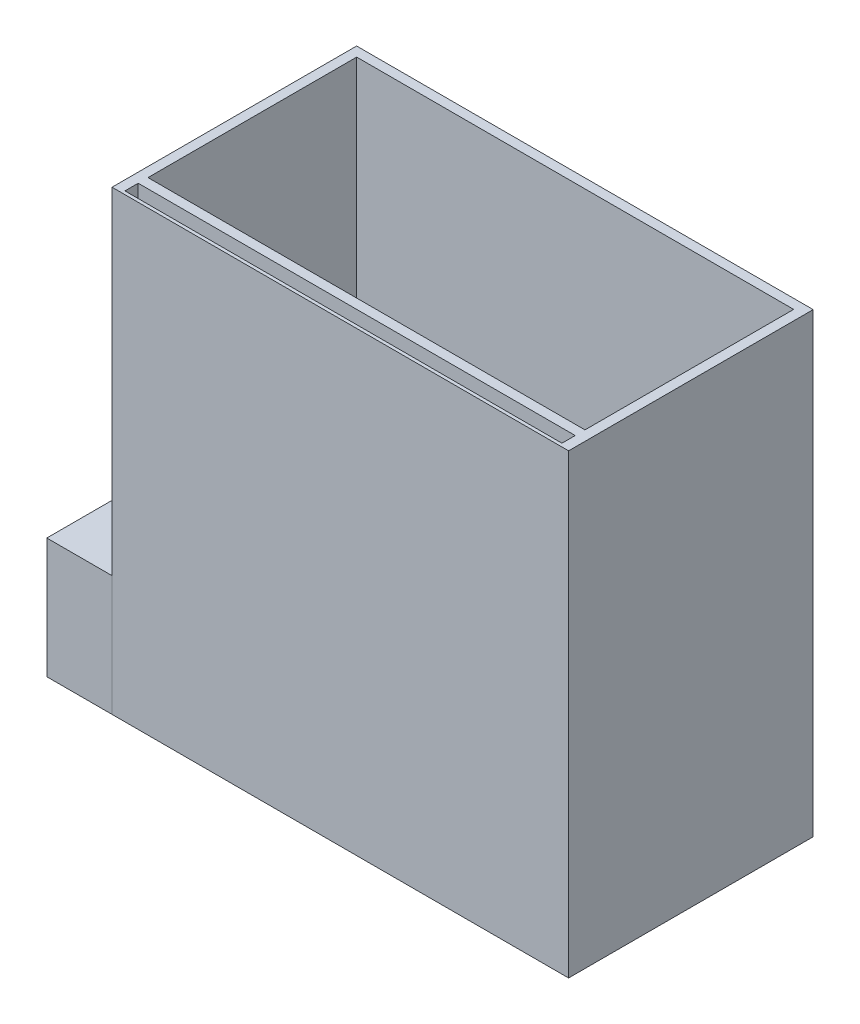
from build123d import *

# Parameters (mm, degrees)
SKETCH1_W           = 140
SKETCH1_H           = 70
BOSS_EXTRUDE1_DEPTH = 140
SKETCH2_W           = 134
SKETCH2_H           = 64
CUT_EXTRUDE1_DEPTH  = 133
SKETCH5_W           = 75.000260503
SKETCH5_H           = 36.846473491
BOSS_EXTRUDE3_DEPTH = 20
SKETCH6_W           = 5.75
SKETCH6_H           = 13
CUT_EXTRUDE2_DEPTH  = 3
SKETCH9_W           = 17
SKETCH9_H           = 30.85
CUT_EXTRUDE3_DEPTH  = 67
SKETCH11_W          = 140
SKETCH11_H          = 140
BOSS_EXTRUDE5_DEPTH = 5
SKETCH15_W          = 134
SKETCH15_H          = 4.072298399
CUT_EXTRUDE4_DEPTH  = 137


with BuildPart() as part:
    # Sketch1 → Boss-Extrude1 (new body)
    with BuildSketch(Plane(origin=(0, 0, 0), x_dir=(1, 0, 0), z_dir=(0, 1, 0))):
        with Locations((-46.886792453, 23.003144654)):
            Rectangle(SKETCH1_W, SKETCH1_H)
    extrude(amount=BOSS_EXTRUDE1_DEPTH)

    # Sketch2 → Cut-Extrude1 (cut)
    with BuildSketch(Plane(origin=(0, 140, 0), x_dir=(1, 0, 0), z_dir=(0, 1, 0))):
        with Locations((-46.932929257, 23.070074841)):
            Rectangle(SKETCH2_W, SKETCH2_H)
    extrude(amount=-CUT_EXTRUDE1_DEPTH, mode=Mode.SUBTRACT)

    # Sketch5 → Boss-Extrude3 (add)
    with BuildSketch(Plane.ZY.offset(116.886792453)):
        with Locations((-20.503014402, 18.423236746)):
            Rectangle(SKETCH5_W, SKETCH5_H)
    extrude(amount=BOSS_EXTRUDE3_DEPTH)

    # Sketch6 → Cut-Extrude2 (cut)
    with BuildSketch(Plane(origin=(0, 0, -58.003144654), x_dir=(-1, 0, 0), z_dir=(0, 0, -1))):
        with Locations((119.761792453, 20.746473491)):
            Rectangle(SKETCH6_W, SKETCH6_H)
    extrude(amount=-CUT_EXTRUDE2_DEPTH, mode=Mode.SUBTRACT)

    # Sketch9 → Cut-Extrude3 (cut)
    with BuildSketch(Plane.XY.offset(11.996855346)):
        with Locations((-125.382389836, 18.421473491)):
            Rectangle(SKETCH9_W, SKETCH9_H)
    extrude(amount=-CUT_EXTRUDE3_DEPTH, mode=Mode.SUBTRACT)

    # Sketch11 → Boss-Extrude5 (add)
    with BuildSketch(Plane.XY.offset(11.996855346)):
        with Locations((-46.886792453, 70)):
            Rectangle(SKETCH11_W, SKETCH11_H)
    extrude(amount=BOSS_EXTRUDE5_DEPTH)

    # Sketch15 → Cut-Extrude4 (cut)
    with BuildSketch(Plane(origin=(0, 140, 0), x_dir=(1, 0, 0), z_dir=(0, 1, 0))):
        with Locations((-46.932929257, -13.963840405)):
            Rectangle(SKETCH15_W, SKETCH15_H)
    extrude(amount=-CUT_EXTRUDE4_DEPTH, mode=Mode.SUBTRACT)


solid = part.part
